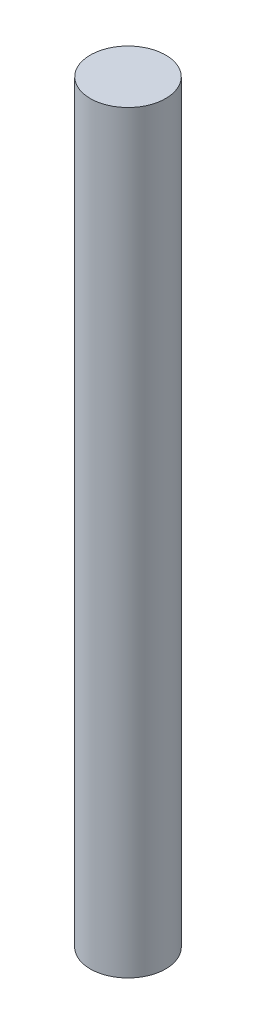
from build123d import *

# Parameters (mm, degrees)
SKETCH5_R           = 3
BOSS_EXTRUDE3_DEPTH = 60


with BuildPart() as part:
    # Sketch5 → Boss-Extrude3 (new body)
    with BuildSketch(Plane(origin=(0, 0, 0), x_dir=(1, 0, 0), z_dir=(0, 1, 0))):
        Circle(SKETCH5_R)
    extrude(amount=BOSS_EXTRUDE3_DEPTH)


solid = part.part
